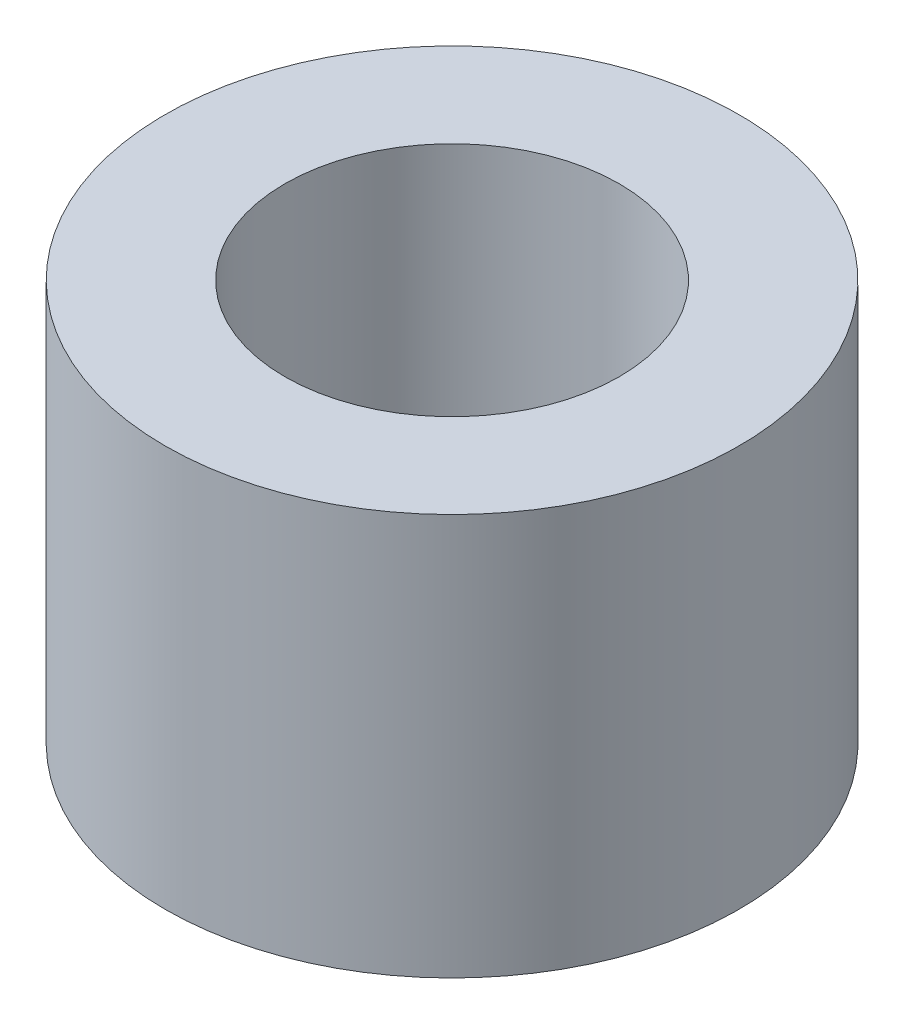
from build123d import *

# Parameters (mm, degrees)
PROFILE_SKETCH_R      = 7.1501
PROFILE_SKETCH_R_2    = 4.1656
PROFILE_EXTRUDE_DEPTH = 10


with BuildPart() as part:
    # Profile Sketch → Profile Extrude (new body)
    with BuildSketch(Plane(origin=(0, 0, 0), x_dir=(1, 0, 0), z_dir=(0, 1, 0))):
        Circle(PROFILE_SKETCH_R)
        Circle(PROFILE_SKETCH_R_2, mode=Mode.SUBTRACT)
    extrude(amount=PROFILE_EXTRUDE_DEPTH)


solid = part.part
